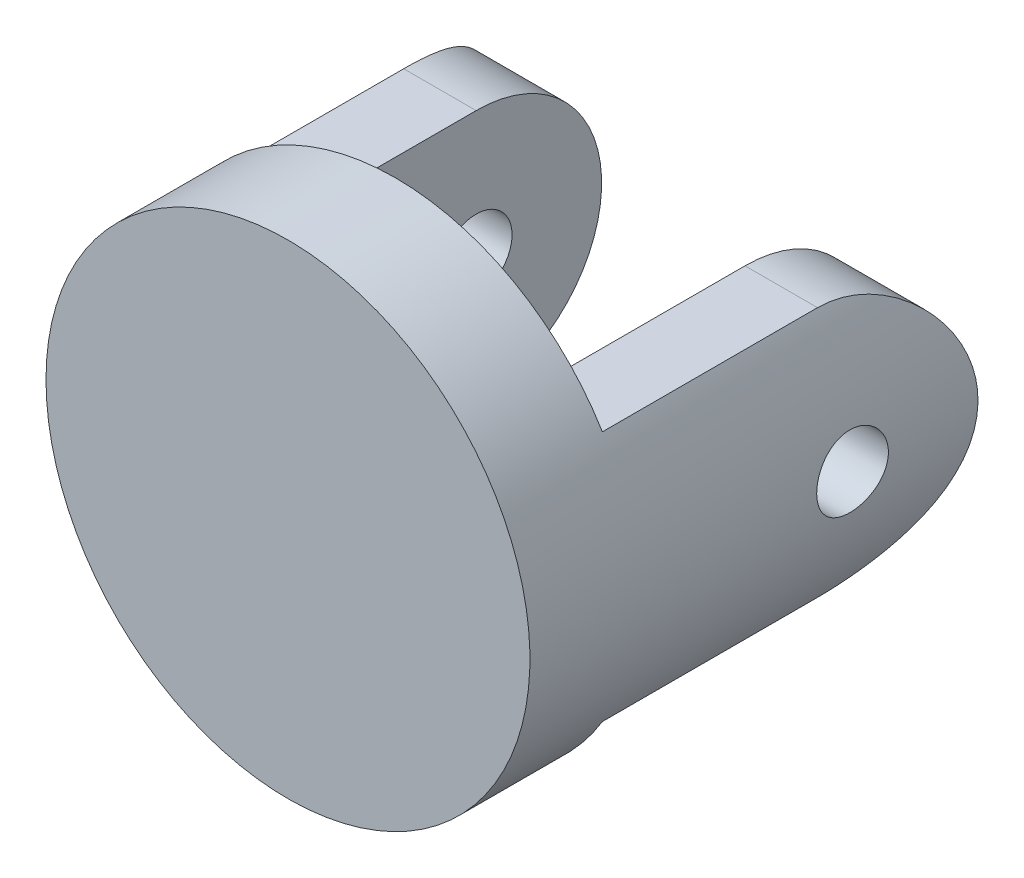
from build123d import *

# Parameters (mm, degrees)
SKETCH2_R                = 6.75
U_JOINT_BASE_DEPTH       = 3
U_JOINT_STANDUPS_DEPTH   = 9.5
STANDUP_ROUND_DEPTH      = 7.75
STANDUP_ROUND_DEPTH_BACK = 7.75
SKETCH5_R                = 1
BALL_HOLES_DEPTH         = 7.75
BALL_HOLES_DEPTH_BACK    = 7.75


with BuildPart() as part:
    # Sketch2 → U Joint Base (new body)
    with BuildSketch(Plane(origin=(0, 0, 0), x_dir=(-1, 0, 0), z_dir=(0, 0, -1))):
        Circle(SKETCH2_R)
    extrude(amount=U_JOINT_BASE_DEPTH)

    # Sketch3 → U Joint Standups (add)
    with BuildSketch(Plane(origin=(0, 0, -3), x_dir=(-1, 0, 0), z_dir=(0, 0, -1))):
        with BuildLine():
            Line((-5.771698, 3.5), (-3.75, 3.5))
            Line((-3.75, 3.5), (-3.75, -3.5))
            Line((-3.75, -3.5), (-5.771698, -3.5))
            ThreePointArc((-5.771698, -3.5), (-6.75, 0), (-5.771698, 3.5))
        make_face()
        with BuildLine():
            Line((3.75, -3.5), (3.75, 3.5))
            Line((3.75, 3.5), (5.771698, 3.5))
            ThreePointArc((5.771698, 3.5), (6.75, 0), (5.771698, -3.5))
            Line((5.771698, -3.5), (3.75, -3.5))
        make_face()
    extrude(amount=U_JOINT_STANDUPS_DEPTH)

    # Sketch4 → Standup Round (cut, two sides)
    with BuildSketch(Plane(origin=(0, 0, 0), x_dir=(0, 0, -1), z_dir=(1, 0, 0))) as standup_round_sk:
        with BuildLine():
            ThreePointArc((9, -3.5), (11.474874, -2.474874), (12.5, 0))
            Line((12.5, 0), (12.5, -3.5))
            Line((12.5, -3.5), (9, -3.5))
        make_face()
        with BuildLine():
            ThreePointArc((12.5, 0), (11.474874, 2.474874), (9, 3.5))
            Line((9, 3.5), (12.5, 3.5))
            Line((12.5, 3.5), (12.5, 0))
        make_face()
    extrude(amount=STANDUP_ROUND_DEPTH, mode=Mode.SUBTRACT)
    extrude(standup_round_sk.sketch, amount=-STANDUP_ROUND_DEPTH_BACK, mode=Mode.SUBTRACT)

    # Sketch5 → Ball Holes (cut, two sides)
    with BuildSketch(Plane(origin=(0, 0, 0), x_dir=(0, 0, -1), z_dir=(1, 0, 0))) as ball_holes_sk:
        with Locations((9, 0)):
            Circle(SKETCH5_R)
    extrude(amount=BALL_HOLES_DEPTH, mode=Mode.SUBTRACT)
    extrude(ball_holes_sk.sketch, amount=-BALL_HOLES_DEPTH_BACK, mode=Mode.SUBTRACT)


solid = part.part
